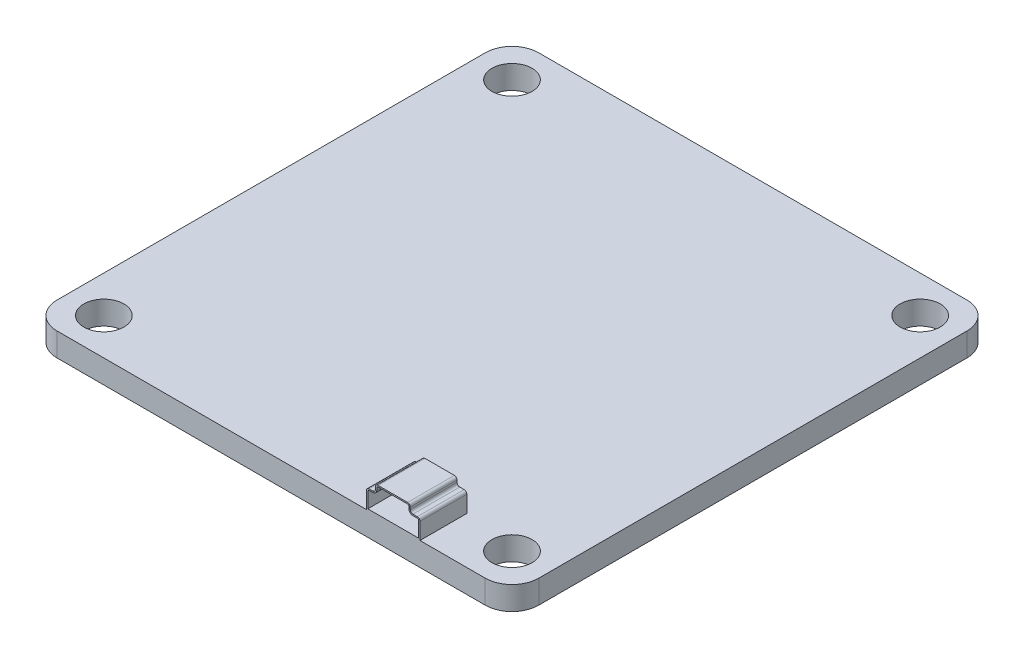
from build123d import *

# Parameters (mm, degrees)
SKETCH2_R           = 1.5
BOSS_EXTRUDE1_DEPTH = 1.75
BOSS_EXTRUDE2_DEPTH = 3
BOSS_EXTRUDE3_DEPTH = 0.5
SKETCH5_R           = 0.25
CUT_EXTRUDE1_DEPTH  = 4.5


with BuildPart() as part:
    # Sketch2 → Boss-Extrude1 (new body)
    with BuildSketch(Plane(origin=(0, 0, 0), x_dir=(1, 0, 0), z_dir=(0, 1, 0))):
        with BuildLine():
            Line((-16, 18), (16, 18))
            ThreePointArc((16, 18), (17.414213562, 17.414213562), (18, 16))
            Line((18, 16), (18, -16))
            ThreePointArc((18, -16), (17.414213562, -17.414213562), (16, -18))
            Line((16, -18), (-16, -18))
            ThreePointArc((-16, -18), (-17.414213562, -17.414213562), (-18, -16))
            Line((-18, -16), (-18, 16))
            ThreePointArc((-18, 16), (-17.414213562, 17.414213562), (-16, 18))
        make_face()
        with Locations((-15.25, 15.25)):
            Circle(SKETCH2_R, mode=Mode.SUBTRACT)
        with Locations((15.25, 15.25)):
            Circle(SKETCH2_R, mode=Mode.SUBTRACT)
        with Locations((15.25, -15.25)):
            Circle(SKETCH2_R, mode=Mode.SUBTRACT)
        with Locations((-15.25, -15.25)):
            Circle(SKETCH2_R, mode=Mode.SUBTRACT)
    extrude(amount=BOSS_EXTRUDE1_DEPTH)

    # Sketch3 → Boss-Extrude2 (add)
    with BuildSketch(Plane.XY.offset(18)):
        with BuildLine():
            Line((7.124530098, 1.75), (11.124530098, 1.75))
            Line((11.124530098, 1.75), (11.124530098, 2.99232659))
            ThreePointArc((11.124530098, 2.99232659), (11.065951454, 3.133747946), (10.924530098, 3.19232659))
            Line((10.924530098, 3.19232659), (10.595445321, 3.19232659))
            ThreePointArc((10.595445321, 3.19232659), (10.454023965, 3.250905233), (10.395445321, 3.39232659))
            Line((10.395445321, 3.39232659), (10.395445321, 3.55))
            ThreePointArc((10.395445321, 3.55), (10.336866677, 3.691421356), (10.195445321, 3.75))
            Line((10.195445321, 3.75), (7.993768929, 3.75))
            ThreePointArc((7.993768929, 3.75), (7.852347573, 3.691421356), (7.793768929, 3.55))
            Line((7.793768929, 3.55), (7.793768929, 3.39232659))
            ThreePointArc((7.793768929, 3.39232659), (7.735190286, 3.250905233), (7.593768929, 3.19232659))
            Line((7.593768929, 3.19232659), (7.324530098, 3.19232659))
            ThreePointArc((7.324530098, 3.19232659), (7.183108742, 3.133747946), (7.124530098, 2.99232659))
            Line((7.124530098, 2.99232659), (7.124530098, 1.75))
        make_face()
        with BuildLine():
            Line((7.993768929, 3.65), (10.195445321, 3.65))
            ThreePointArc((10.195445321, 3.65), (10.266155999, 3.620710678), (10.295445321, 3.55))
            Line((10.295445321, 3.55), (10.295445321, 3.39232659))
            ThreePointArc((10.295445321, 3.39232659), (10.383313287, 3.180194555), (10.595445321, 3.09232659))
            Line((10.595445321, 3.09232659), (10.924530098, 3.09232659))
            ThreePointArc((10.924530098, 3.09232659), (10.995240776, 3.063037268), (11.024530098, 2.99232659))
            Line((11.024530098, 2.99232659), (11.024530098, 1.85))
            Line((11.024530098, 1.85), (7.224530098, 1.85))
            Line((7.224530098, 1.85), (7.224530098, 2.99232659))
            ThreePointArc((7.224530098, 2.99232659), (7.25381942, 3.063037268), (7.324530098, 3.09232659))
            Line((7.324530098, 3.09232659), (7.593768929, 3.09232659))
            ThreePointArc((7.593768929, 3.09232659), (7.805900964, 3.180194555), (7.893768929, 3.39232659))
            Line((7.893768929, 3.39232659), (7.893768929, 3.55))
            ThreePointArc((7.893768929, 3.55), (7.923058251, 3.620710678), (7.993768929, 3.65))
        make_face(mode=Mode.SUBTRACT)
    extrude(amount=-BOSS_EXTRUDE2_DEPTH)

    # Sketch4 → Boss-Extrude3 (add)
    with BuildSketch(Plane(origin=(0, 0, 15), x_dir=(-1, 0, 0), z_dir=(0, 0, -1))):
        with BuildLine():
            Line((-7.124530098, 1.75), (-7.124530098, 2.99232659))
            ThreePointArc((-7.124530098, 2.99232659), (-7.183108742, 3.133747946), (-7.324530098, 3.19232659))
            Line((-7.324530098, 3.19232659), (-7.593768929, 3.19232659))
            ThreePointArc((-7.593768929, 3.19232659), (-7.735190286, 3.250905233), (-7.793768929, 3.39232659))
            Line((-7.793768929, 3.39232659), (-7.793768929, 3.55))
            ThreePointArc((-7.793768929, 3.55), (-7.852347573, 3.691421356), (-7.993768929, 3.75))
            Line((-7.993768929, 3.75), (-10.195445321, 3.75))
            ThreePointArc((-10.195445321, 3.75), (-10.336866677, 3.691421356), (-10.395445321, 3.55))
            Line((-10.395445321, 3.55), (-10.395445321, 3.39232659))
            ThreePointArc((-10.395445321, 3.39232659), (-10.454023965, 3.250905233), (-10.595445321, 3.19232659))
            Line((-10.595445321, 3.19232659), (-10.924530098, 3.19232659))
            ThreePointArc((-10.924530098, 3.19232659), (-11.065951454, 3.133747946), (-11.124530098, 2.99232659))
            Line((-11.124530098, 2.99232659), (-11.124530098, 1.75))
            Line((-11.124530098, 1.75), (-7.124530098, 1.75))
        make_face()
    extrude(amount=BOSS_EXTRUDE3_DEPTH)

    # Sketch5 → Cut-Extrude1 (cut, through all)
    with BuildSketch(Plane(origin=(0, 0, 14.5), x_dir=(-1, 0, 0), z_dir=(0, 0, -1))):
        with Locations((-10.152838139, 2.618092042)):
            Circle(SKETCH5_R)
        with Locations((-9.352838139, 2.618092042)):
            Circle(SKETCH5_R)
        with Locations((-8.552838139, 2.618092042)):
            Circle(SKETCH5_R)
    extrude(amount=-CUT_EXTRUDE1_DEPTH, mode=Mode.SUBTRACT)


solid = part.part
